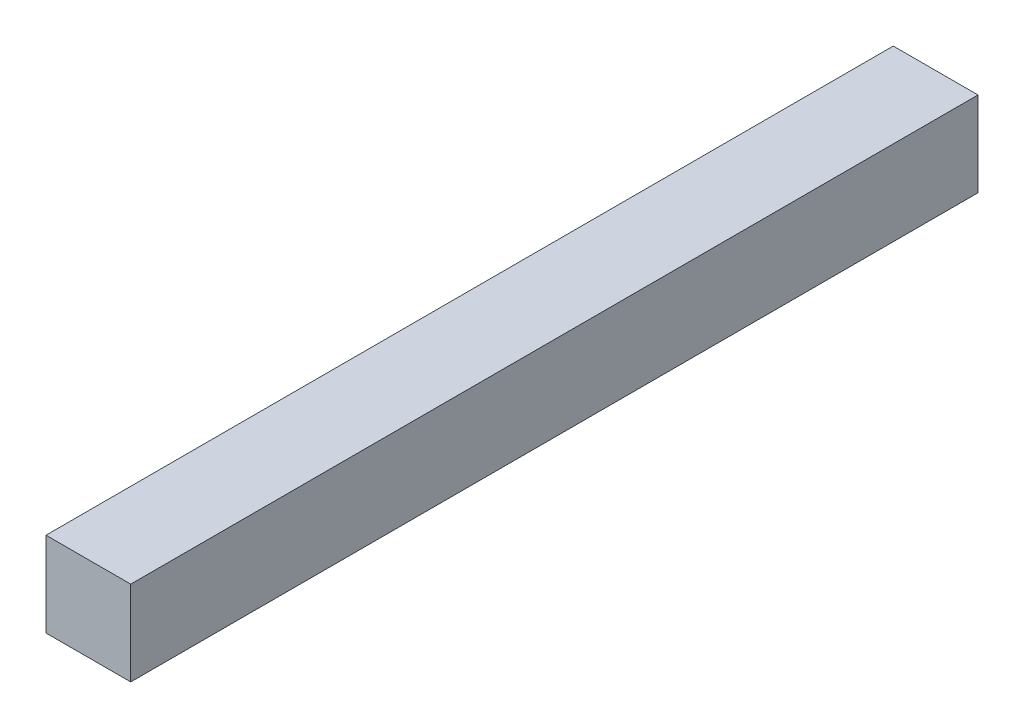
from build123d import *

# Parameters (mm, degrees)
SKETCH1_W           = 3
SKETCH1_H           = 3
BOSS_EXTRUDE1_DEPTH = 30


with BuildPart() as part:
    # Sketch1 → Boss-Extrude1 (new body)
    with BuildSketch(Plane.XY):
        Rectangle(SKETCH1_W, SKETCH1_H)
    extrude(amount=BOSS_EXTRUDE1_DEPTH)


solid = part.part
